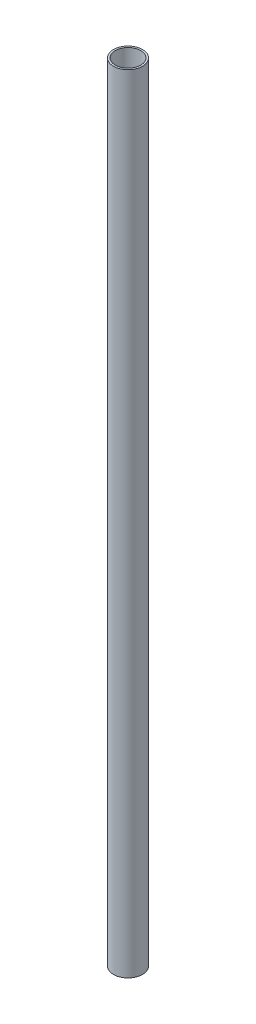
from build123d import *

# Parameters (mm, degrees)
SKETCH1_R      = 9.525
SKETCH1_R_2    = 8.325
EXTRUDE1_DEPTH = 516


with BuildPart() as part:
    # Sketch1 → Extrude1 (new body)
    with BuildSketch(Plane(origin=(0, -521.327437838, 0), x_dir=(1, 0, 0), z_dir=(0, 1, 0))):
        Circle(SKETCH1_R)
        Circle(SKETCH1_R_2, mode=Mode.SUBTRACT)
    extrude(amount=EXTRUDE1_DEPTH)


solid = part.part
